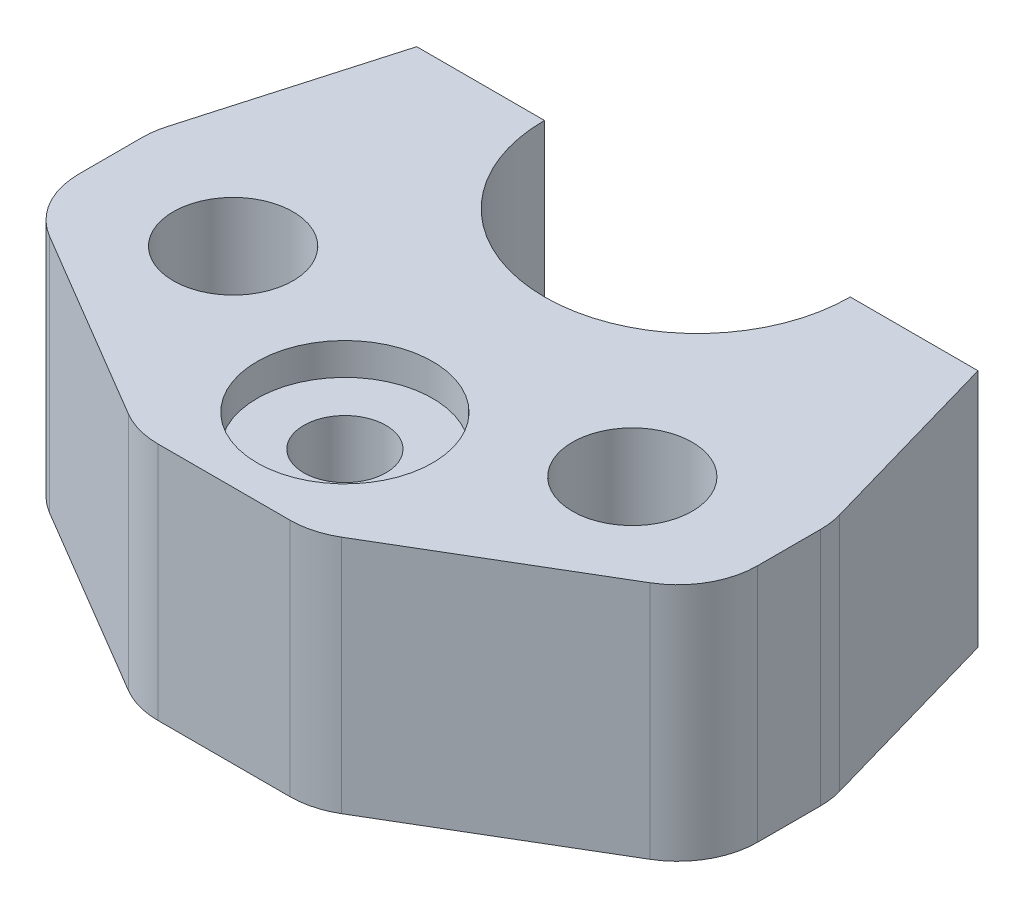
from build123d import *

# Parameters (mm, degrees)
SKETCH2_R           = 7.5
SKETCH2_R_2         = 5.15
BOSS_EXTRUDE1_DEPTH = 30
FILLET1_R           = 10
SKETCH4_R           = 11
CUT_EXTRUDE1_DEPTH  = 4


with BuildPart() as part:
    # Sketch2 → Boss-Extrude1 (new body)
    with BuildSketch(Plane(origin=(0, 0, 0), x_dir=(1, 0, 0), z_dir=(0, 1, 0))):
        with BuildLine():
            Line((35.15, 0), (19.15, 0))
            ThreePointArc((19.15, 0), (0, -19.15), (-19.15, 0))
            Line((-19.15, 0), (-35.15, 0))
            Line((-35.15, 0), (-42.5, -25.65))
            Line((-42.5, -25.65), (-42.5, -40.65))
            Line((-42.5, -40.65), (-11, -59.3))
            Line((-11, -59.3), (11, -59.3))
            Line((11, -59.3), (42.5, -40.65))
            Line((42.5, -40.65), (42.5, -25.65))
            Line((42.5, -25.65), (35.15, 0))
        make_face()
        with Locations((-25, -33.15)):
            Circle(SKETCH2_R, mode=Mode.SUBTRACT)
        with Locations((25, -33.15)):
            Circle(SKETCH2_R, mode=Mode.SUBTRACT)
        with Locations((0, -44.15)):
            Circle(SKETCH2_R_2, mode=Mode.SUBTRACT)
    extrude(amount=BOSS_EXTRUDE1_DEPTH)

    # Fillet1
    fillet1_edges = [part.edges().sort_by_distance(p)[0] for p in [
        (42.5, 15, 25.65),
        (42.5, 15, 40.65),
        (11, 15, 59.3),
        (-11, 15, 59.3),
        (-42.5, 15, 40.65),
        (-42.5, 15, 25.65),
    ]]
    fillet(fillet1_edges, radius=FILLET1_R)

    # Sketch4 → Cut-Extrude1 (cut)
    with BuildSketch(Plane(origin=(0, 30, 0), x_dir=(1, 0, 0), z_dir=(0, 1, 0))):
        with Locations((0, -44.15)):
            Circle(SKETCH4_R)
    extrude(amount=-CUT_EXTRUDE1_DEPTH, mode=Mode.SUBTRACT)


solid = part.part
